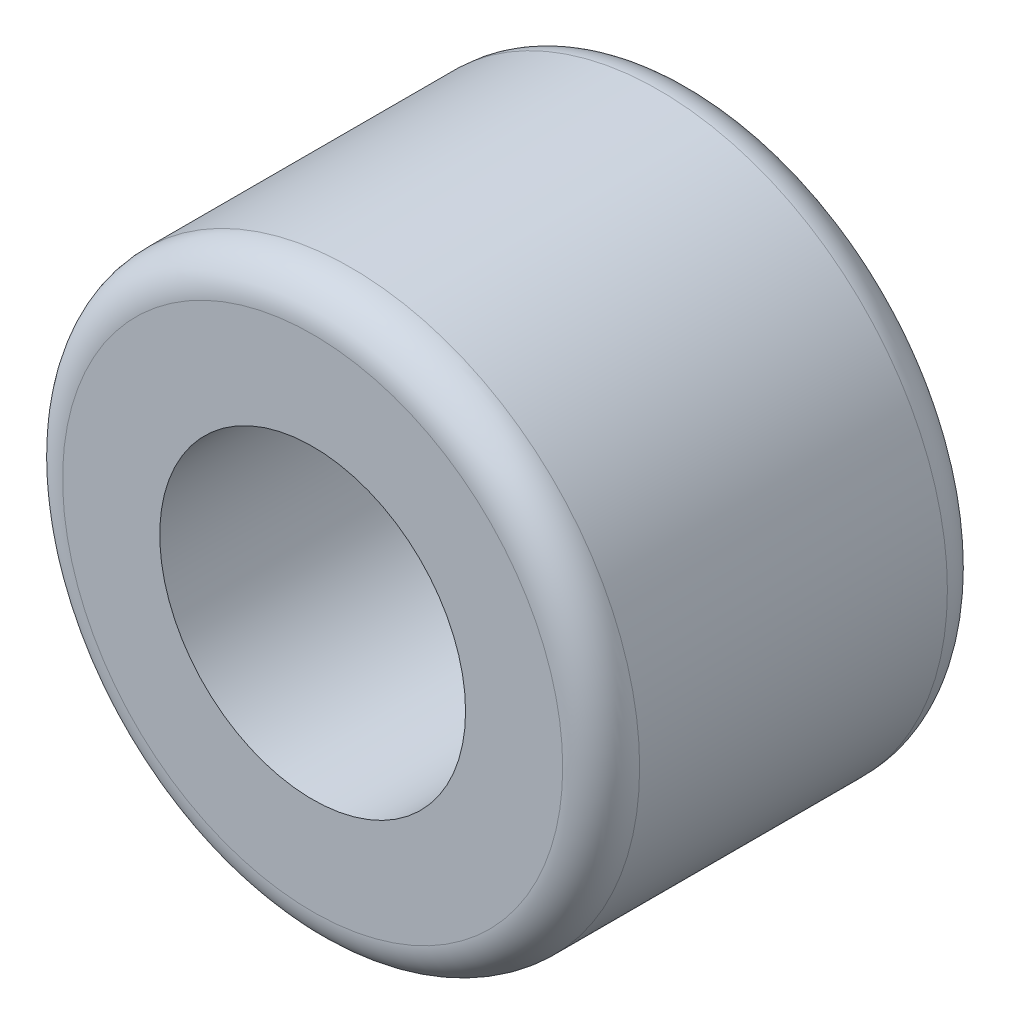
from build123d import *

# Parameters (mm, degrees)
CROQUIS1_R              = 7.5
CROQUIS1_R_2            = 3.975
SALIENTE_EXTRUIR1_DEPTH = 5
REDONDEO2_R             = 1


with BuildPart() as part:
    # Croquis1 → Saliente-Extruir1 (new body, symmetric)
    with BuildSketch(Plane.XY):
        Circle(CROQUIS1_R)
        Circle(CROQUIS1_R_2, mode=Mode.SUBTRACT)
    extrude(amount=SALIENTE_EXTRUIR1_DEPTH, both=True)

    # Redondeo2
    redondeo2_edges = [part.edges().sort_by_distance(p)[0] for p in [
        (-7.5, 0, -5),
        (-7.5, 0, 5),
    ]]
    fillet(redondeo2_edges, radius=REDONDEO2_R)


solid = part.part
